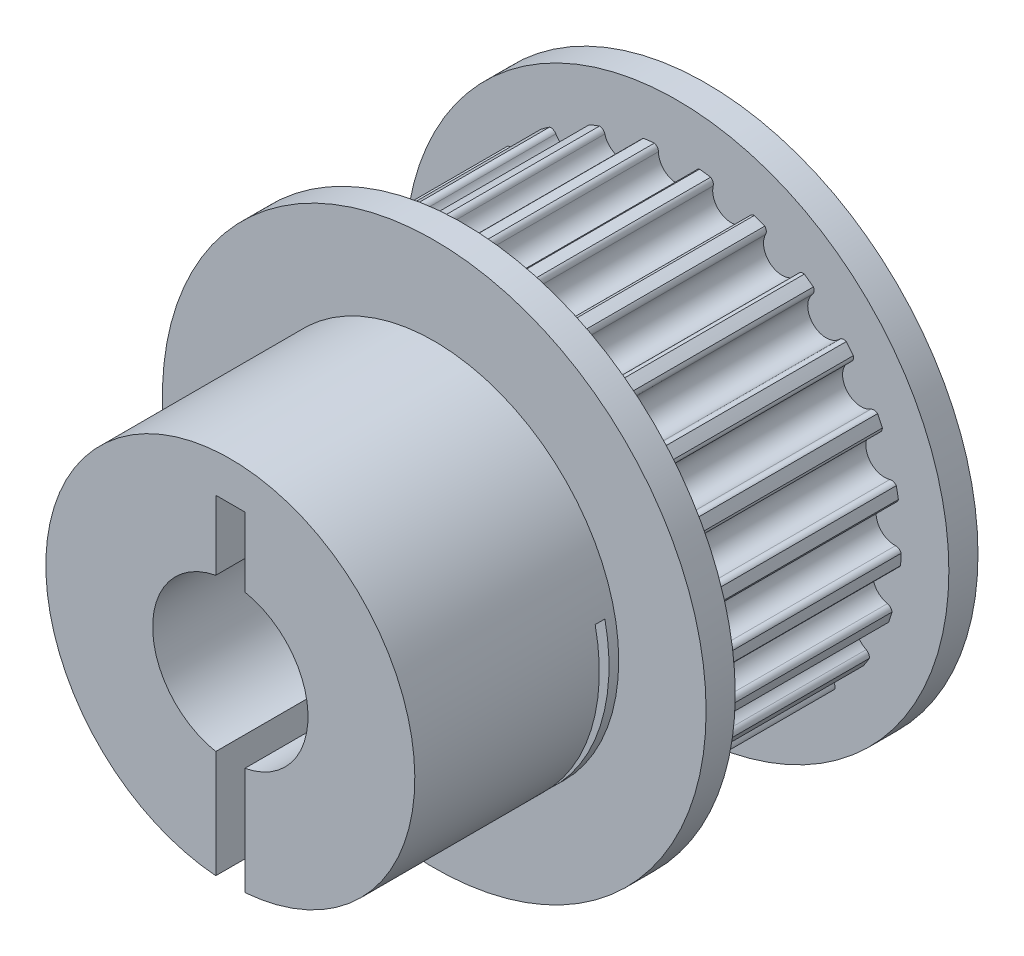
from build123d import *

# Parameters (mm, degrees)
SKETCH_1_R               = 11.555
EXTRUDE_1_DEPTH          = 11
CUT_EXTRUDE_1_REACH      = 21.699
PATTERN_CIRCULAR_1_COUNT = 25
SKETCH_3_R               = 14
EXTRUDE_2_DEPTH          = 1.5
SKETCH_4_R               = 9.5
EXTRUDE_3_DEPTH          = 10.5
CUT_EXTRUDE_START        = -10
CUT_EXTRUDE_2_DEPTH      = 0.5
CUT_EXTRUDE_3_REACH      = 33.5
SKETCH_6_R               = 4
CUT_EXTRUDE_4_REACH      = 33.5
CUT_EXTRUDE_6_DEPTH      = 0.75
CUT_EXTRUDE_6_DEPTH_BACK = 0.75


with BuildPart() as part:
    # 草圖1 → 填料-伸長1 (new body)
    with BuildSketch(Plane.XY):
        Circle(SKETCH_1_R)
    extrude(amount=EXTRUDE_1_DEPTH)

    # 草圖2 → 除料-伸長1 (cut, up to next)
    with BuildSketch(Plane.XY.offset(11), mode=Mode.PRIVATE) as cut_extrude_1_sk1:
        with BuildLine():
            ThreePointArc((1.162550039, 11.496369097), (0, 11.555), (-1.162550039, 11.496369097))
            ThreePointArc((-1.162550039, 11.496369097), (-1.013703117, 11.389263051), (-0.955, 11.215536094))
            ThreePointArc((-0.955, 11.215536094), (0, 10.275), (0.955, 11.215536094))
            ThreePointArc((0.955, 11.215536094), (1.013703117, 11.389263051), (1.162550039, 11.496369097))
        make_face()
    cut_extrude_1_tool1 = extrude(cut_extrude_1_sk1.sketch, amount=-CUT_EXTRUDE_1_REACH, mode=Mode.PRIVATE) & part.part
    cut_extrude_1 = cut_extrude_1_tool1.solids().sort_by_distance((0, 10.99734, 11))[0]
    add(cut_extrude_1, mode=Mode.SUBTRACT)

    # 環狀複製排列1: 除料-伸長1 ×25 about axis
    pattern_circular_1_axis = Axis((0, 0, 11), (0, 0, 1))
    for i in range(1, PATTERN_CIRCULAR_1_COUNT):
        add(cut_extrude_1.rotate(pattern_circular_1_axis, i * 360 / PATTERN_CIRCULAR_1_COUNT), mode=Mode.SUBTRACT)

    # 草圖3 → 填料-伸長2 (add)
    with BuildSketch(Plane.XY.offset(11)):
        Circle(SKETCH_3_R)
    extrude_2 = extrude(amount=EXTRUDE_2_DEPTH)

    # 鏡射1: 填料-伸長2 across plane
    add(extrude_2.mirror(Plane(origin=(0, 0, 5.5), x_dir=(1, 0, 0), z_dir=(0, 0, -1))))

    # 草圖4 → 填料-伸長3 (add)
    with BuildSketch(Plane.XY.offset(12.5)):
        Circle(SKETCH_4_R)
    extrude(amount=EXTRUDE_3_DEPTH)

    # 草圖5 → 除料-伸長2 (cut)
    with BuildSketch(Plane.XY.offset(23).offset(CUT_EXTRUDE_START)):
        with BuildLine():
            Line((-9.287087811, 2), (9.287087811, 2))
            ThreePointArc((9.287087811, 2), (0, -9.5), (-9.287087811, 2))
        make_face()
    extrude(amount=CUT_EXTRUDE_2_DEPTH, mode=Mode.SUBTRACT)

    # 草圖6 → 除料-伸長3 (cut, up to next)
    with BuildSketch(Plane.XY.offset(23), mode=Mode.PRIVATE) as cut_extrude_3_sk1:
        Circle(SKETCH_6_R)
    cut_extrude_3_tool1 = extrude(cut_extrude_3_sk1.sketch, amount=-CUT_EXTRUDE_3_REACH, mode=Mode.PRIVATE) & part.part
    add(cut_extrude_3_tool1.solids().sort_by_distance((0, 0, 23))[0], mode=Mode.SUBTRACT)

    # 草圖7 → 除料-伸長4 (cut, up to next)
    with BuildSketch(Plane.XY.offset(23), mode=Mode.PRIVATE) as cut_extrude_4_sk1:
        with BuildLine():
            Line((-0.75, -3.929058411), (-0.75, -9.470348462))
            ThreePointArc((-0.75, -9.470348462), (0, -9.5), (0.75, -9.470348462))
            Line((0.75, -9.470348462), (0.75, -3.929058411))
            ThreePointArc((0.75, -3.929058411), (0, -4), (-0.75, -3.929058411))
        make_face()
    cut_extrude_4_tool1 = extrude(cut_extrude_4_sk1.sketch, amount=-CUT_EXTRUDE_4_REACH, mode=Mode.PRIVATE) & part.part
    add(cut_extrude_4_tool1.solids().sort_by_distance((0, -6.733246, 23))[0], mode=Mode.SUBTRACT)

    # 草圖8 → 除料-伸長6 (cut, two sides: drawn at the far end of the back side and taken through both)
    with BuildSketch(Plane(origin=(0, 0, 0), x_dir=(0, 0, -1), z_dir=(1, 0, 0)).offset(-CUT_EXTRUDE_6_DEPTH_BACK)):
        Polygon((-23, 7.5), (-18.5, 3.5), (-23, 3.5), align=None)
    extrude(amount=CUT_EXTRUDE_6_DEPTH + CUT_EXTRUDE_6_DEPTH_BACK, mode=Mode.SUBTRACT)


solid = part.part
